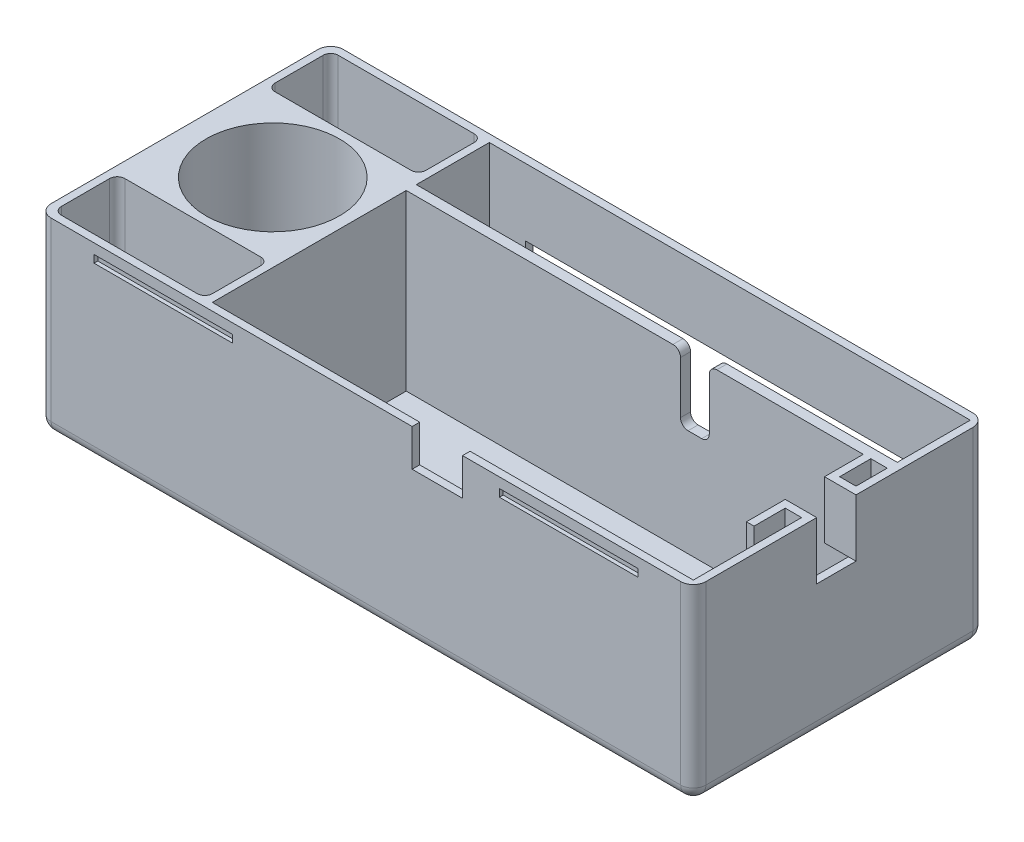
from build123d import *

# Parameters (mm, degrees)
SKETCH1_W           = 260
SKETCH1_H           = 116
BOSS_EXTRUDE1_DEPTH = 75
SKETCH2_R           = 26.5
SKETCH2_W           = 191
SKETCH2_H           = 29
SKETCH2_H_2         = 77
SKETCH2_W_2         = 60
SKETCH2_H_3         = 25.123653406
SKETCH2_H_4         = 25.23272894
CUT_EXTRUDE1_DEPTH  = 69
FILLET1_R           = 5
FILLET2_R           = 5
SKETCH4_W           = 11.43
SKETCH4_H           = 4
CUT_EXTRUDE3_DEPTH  = 26.67
FILLET3_R           = 3
SKETCH5_W           = 55
SKETCH5_H           = 3
CUT_EXTRUDE4_DEPTH  = 1.5
SKETCH6_W           = 55
SKETCH6_H           = 3
CUT_EXTRUDE5_DEPTH  = 1.5
FILLET4_R           = 3
SKETCH7_W           = 162.299
SKETCH7_H           = 39.878
CUT_EXTRUDE6_DEPTH  = 10
SKETCH9_W           = 20
SKETCH9_H           = 3
CUT_EXTRUDE7_DEPTH  = 14.7
SKETCH10_W          = 3
SKETCH10_H          = 15.6
CUT_EXTRUDE8_DEPTH  = 22.8
SKETCH11_W          = 3
SKETCH11_H          = 22.8
BOSS_EXTRUDE2_DEPTH = 6.5
SKETCH12_W          = 15.39
SKETCH12_H          = 22.8
BOSS_EXTRUDE3_DEPTH = 3
SKETCH13_R          = 12.5
CUT_EXTRUDE9_DEPTH  = 3


with BuildPart() as part:
    # Sketch1 → Boss-Extrude1 (new body)
    with BuildSketch(Plane(origin=(0, 0, 0), x_dir=(1, 0, 0), z_dir=(0, 1, 0))):
        with Locations((130, 58)):
            Rectangle(SKETCH1_W, SKETCH1_H)
    extrude(amount=BOSS_EXTRUDE1_DEPTH)

    # Sketch2 → Cut-Extrude1 (cut)
    with BuildSketch(Plane(origin=(0, 75, 0), x_dir=(1, 0, 0), z_dir=(0, 1, 0))):
        with Locations((35, 58)):
            Circle(SKETCH2_R)
        with Locations((161.5, 98.5)):
            Rectangle(SKETCH2_W, SKETCH2_H)
        with Locations((161.5, 41.5)):
            Rectangle(SKETCH2_W, SKETCH2_H_2)
        with Locations((33, 100.438173297)):
            Rectangle(SKETCH2_W_2, SKETCH2_H_3)
        with Locations((33, 15.61636447)):
            Rectangle(SKETCH2_W_2, SKETCH2_H_4)
    extrude(amount=-CUT_EXTRUDE1_DEPTH, mode=Mode.SUBTRACT)

    # Fillet1
    fillet1_edges = [part.edges().sort_by_distance(p)[0] for p in [
        (0, 37.5, -116),
        (260, 37.5, -116),
        (260, 37.5, 0),
        (0, 37.5, 0),
    ]]
    fillet(fillet1_edges, radius=FILLET1_R)

    # Fillet2
    fillet2_edges = [part.edges().sort_by_distance(p)[0] for p in [
        (130, 0, -116),
        (0, 0, -58),
        (260, 0, -58),
        (130, 0, 0),
        (1.464466094, 0, -114.535533906),
        (1.464466094, 0, -1.464466094),
        (258.535533906, 0, -1.464466094),
        (258.535533906, 0, -114.535533906),
    ]]
    fillet(fillet2_edges, radius=FILLET2_R)

    # Sketch4 → Cut-Extrude3 (cut)
    with BuildSketch(Plane(origin=(0, 75, 0), x_dir=(1, 0, 0), z_dir=(0, 1, 0))):
        with Locations((180.625, 82)):
            Rectangle(SKETCH4_W, SKETCH4_H)
    extrude(amount=-CUT_EXTRUDE3_DEPTH, mode=Mode.SUBTRACT)

    # Fillet3
    fillet3_edges = [part.edges().sort_by_distance(p)[0] for p in [
        (186.34, 48.33, -82),
        (174.91, 48.33, -82),
        (186.34, 75, -82),
        (174.91, 75, -82),
    ]]
    fillet(fillet3_edges, radius=FILLET3_R)

    # Sketch5 → Cut-Extrude4 (cut)
    with BuildSketch(Plane.XY):
        with Locations((49.5, 69.5)):
            Rectangle(SKETCH5_W, SKETCH5_H)
        with Locations((210.5, 69.5)):
            Rectangle(SKETCH5_W, SKETCH5_H)
    extrude(amount=-CUT_EXTRUDE4_DEPTH, mode=Mode.SUBTRACT)

    # Sketch6 → Cut-Extrude5 (cut)
    with BuildSketch(Plane(origin=(0, 0, -116), x_dir=(-1, 0, 0), z_dir=(0, 0, -1))):
        with Locations((-210.5, 69.5)):
            Rectangle(SKETCH6_W, SKETCH6_H)
        with Locations((-49.5, 69.5)):
            Rectangle(SKETCH6_W, SKETCH6_H)
    extrude(amount=-CUT_EXTRUDE5_DEPTH, mode=Mode.SUBTRACT)

    # Fillet4
    fillet4_edges = [part.edges().sort_by_distance(p)[0] for p in [
        (3, 40.5, -87.876346594),
        (3, 40.5, -113),
        (63, 40.5, -113),
        (63, 40.5, -87.876346594),
        (3, 40.5, -3),
        (3, 40.5, -28.23272894),
        (63, 40.5, -28.23272894),
        (63, 40.5, -3),
    ]]
    fillet(fillet4_edges, radius=FILLET4_R)

    # Sketch7 → Cut-Extrude6 (cut)
    with BuildSketch(Plane(origin=(0, 0, -116), x_dir=(-1, 0, 0), z_dir=(0, 0, -1))):
        with Locations((-161.4995, 28.391)):
            Rectangle(SKETCH7_W, SKETCH7_H)
    extrude(amount=-CUT_EXTRUDE6_DEPTH, mode=Mode.SUBTRACT)

    # Sketch9 → Cut-Extrude7 (cut)
    with BuildSketch(Plane(origin=(0, 75, 0), x_dir=(1, 0, 0), z_dir=(0, 1, 0))):
        with Locations((158.35, 1.5)):
            Rectangle(SKETCH9_W, SKETCH9_H)
    extrude(amount=-CUT_EXTRUDE7_DEPTH, mode=Mode.SUBTRACT)

    # Sketch10 → Cut-Extrude8 (cut)
    with BuildSketch(Plane(origin=(0, 75, 0), x_dir=(1, 0, 0), z_dir=(0, 1, 0))):
        with Locations((258.5, 56.81)):
            Rectangle(SKETCH10_W, SKETCH10_H)
    extrude(amount=-CUT_EXTRUDE8_DEPTH, mode=Mode.SUBTRACT)

    # Sketch11 → Boss-Extrude2 (add)
    with BuildSketch(Plane.ZY.offset(-257)):
        with Locations((-47.51, 63.6)):
            Rectangle(SKETCH11_W, SKETCH11_H)
        with Locations((-66.11, 63.6)):
            Rectangle(SKETCH11_W, SKETCH11_H)
    extrude(amount=BOSS_EXTRUDE2_DEPTH)

    # Sketch12 → Boss-Extrude3 (add)
    with BuildSketch(Plane.ZY.offset(-250.5)):
        with Locations((-72.305, 63.6)):
            Rectangle(SKETCH12_W, SKETCH12_H)
        with Locations((-41.315, 63.6)):
            Rectangle(SKETCH12_W, SKETCH12_H)
    extrude(amount=BOSS_EXTRUDE3_DEPTH)

    # Sketch13 → Cut-Extrude9 (cut)
    with BuildSketch(Plane(origin=(0, 6, 0), x_dir=(1, 0, 0), z_dir=(0, 1, 0))):
        with Locations((35, 58)):
            Circle(SKETCH13_R)
    extrude(amount=-CUT_EXTRUDE9_DEPTH, mode=Mode.SUBTRACT)


solid = part.part
